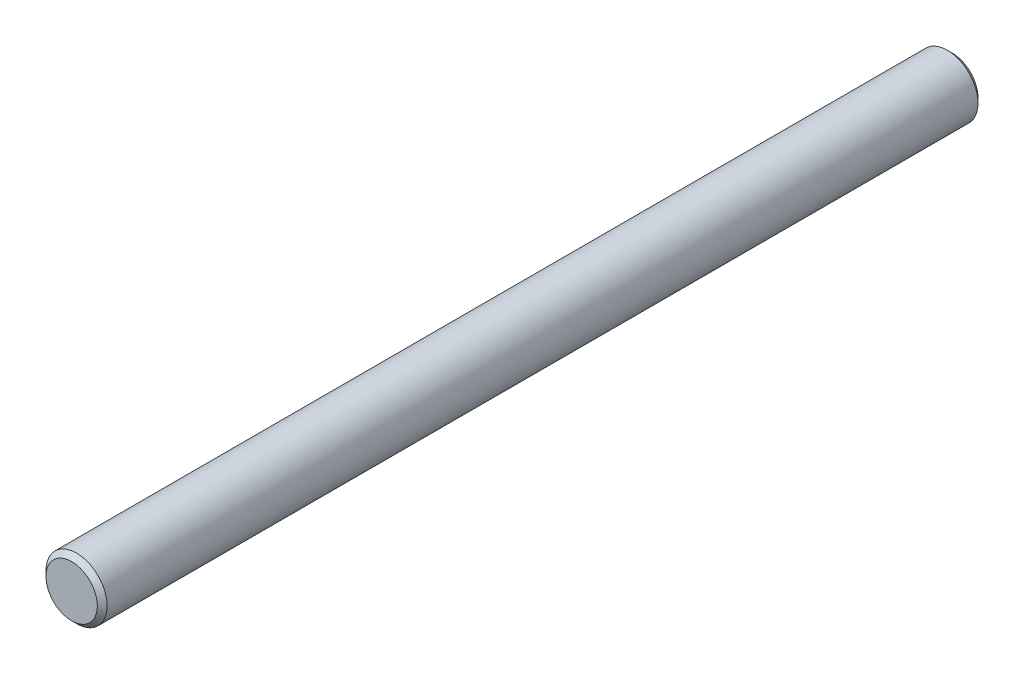
from build123d import *

# Parameters (mm, degrees)
SKETCH1_R           = 1.5875
BOSS_EXTRUDE1_DEPTH = 45.72
CHAMFER1_SIZE       = 0.254


with BuildPart() as part:
    # Sketch1 → Boss-Extrude1 (new body)
    with BuildSketch(Plane.XY):
        Circle(SKETCH1_R)
    extrude(amount=BOSS_EXTRUDE1_DEPTH)

    # Chamfer1
    chamfer1_edges = [part.edges().sort_by_distance(p)[0] for p in [
        (-1.5875, 0, 0),
        (-1.5875, 0, 45.72),
    ]]
    chamfer(chamfer1_edges, length=CHAMFER1_SIZE)


solid = part.part
